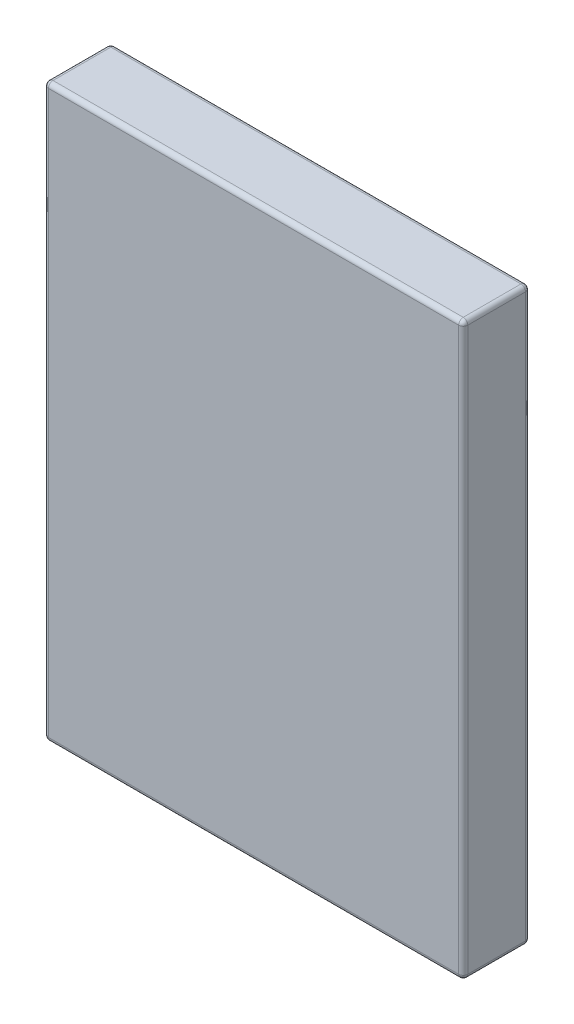
from build123d import *

# Parameters (mm, degrees)
ESBO_O1_W                = 1380
ESBO_O1_H                = 1880
RESSALTO_EXTRUS_O1_DEPTH = 220
FILETE1_R                = 15


with BuildPart() as part:
    # Esboço1 → Ressalto-extrusão1 (new body)
    with BuildSketch(Plane.XY):
        with Locations((690, 940)):
            Rectangle(ESBO_O1_W, ESBO_O1_H)
    extrude(amount=RESSALTO_EXTRUS_O1_DEPTH)

    # Filete1
    filete1_edges = [part.edges().sort_by_distance(p)[0] for p in [
        (1380, 940, 220),
        (690, 1880, 220),
        (0, 940, 220),
        (690, 1880, 0),
        (1380, 940, 0),
        (690, 0, 0),
        (0, 940, 0),
        (0, 1880, 110),
        (1380, 1880, 110),
        (1380, 0, 110),
        (0, 0, 110),
        (690, 0, 220),
    ]]
    fillet(filete1_edges, radius=FILETE1_R)


solid = part.part
